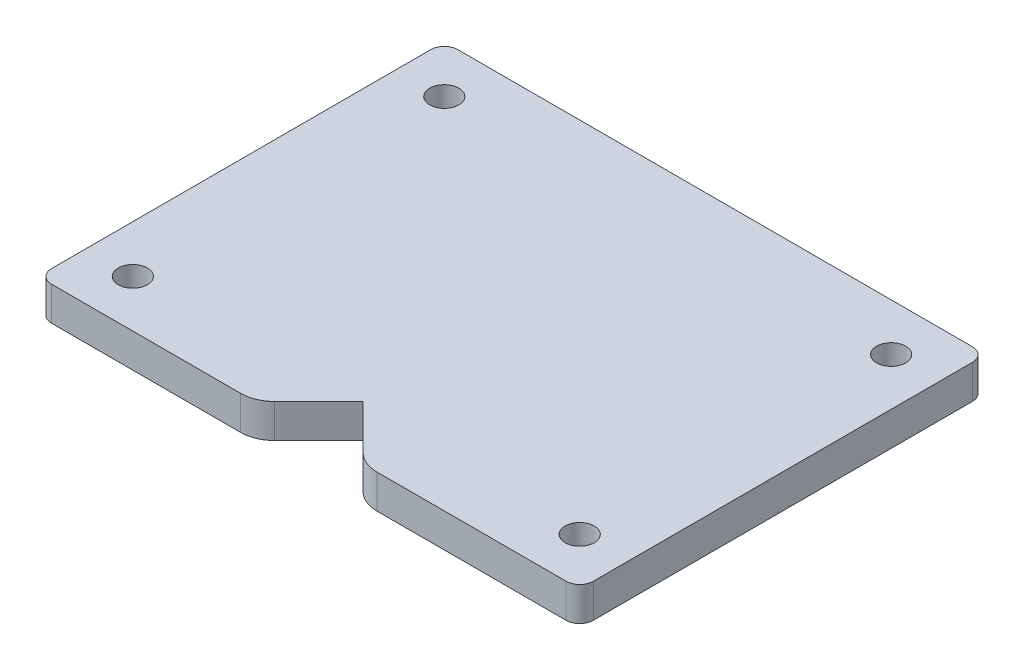
from build123d import *

# Parameters (mm, degrees)
SKETCH1_R           = 5.25
BOSS_EXTRUDE1_DEPTH = 60
SKETCH2_R           = 11.425
CUT_EXTRUDE1_DEPTH  = 8.6
SKETCH3_R           = 14
CUT_EXTRUDE2_DEPTH  = 5
SKETCH4_R           = 1.3
CUT_EXTRUDE3_DEPTH  = 5
SKETCH6_R           = 2.15
CUT_EXTRUDE5_DEPTH  = 6
CUT_EXTRUDE6_DEPTH  = 35
FILLET2_R           = 5
FILLET3_R           = 2
FILLET4_R           = 5
CUT_EXTRUDE7_DEPTH  = 30.05
FILLET5_R           = 5


with BuildPart() as part:
    # Sketch1 → Boss-Extrude1 (new body)
    with BuildSketch(Plane.XY):
        with BuildLine():
            Line((-40, 15.05), (40, 15.05))
            Line((40, 15.05), (40, 10.05))
            Line((40, 10.05), (9.746666097, 10.05))
            ThreePointArc((9.746666097, 10.05), (0, -14), (-9.746666097, 10.05))
            Line((-9.746666097, 10.05), (-40, 10.05))
            Line((-40, 10.05), (-40, 15.05))
        make_face()
        Circle(SKETCH1_R, mode=Mode.SUBTRACT)
    extrude(amount=BOSS_EXTRUDE1_DEPTH)

    # Sketch2 → Cut-Extrude1 (cut)
    with BuildSketch(Plane(origin=(0, 0, 0), x_dir=(-1, 0, 0), z_dir=(0, 0, -1))):
        Circle(SKETCH2_R)
    extrude(amount=-CUT_EXTRUDE1_DEPTH, mode=Mode.SUBTRACT)

    # Sketch3 → Cut-Extrude2 (cut)
    with BuildSketch(Plane(origin=(0, 0, 0), x_dir=(-1, 0, 0), z_dir=(0, 0, -1))):
        Circle(SKETCH3_R)
    extrude(amount=-CUT_EXTRUDE2_DEPTH, mode=Mode.SUBTRACT)

    # Sketch4 → Cut-Extrude3 (cut)
    with BuildSketch(Plane(origin=(0, 0, 8.6), x_dir=(-1, 0, 0), z_dir=(0, 0, -1))):
        with Locations((5.656854249, 5.656854249)):
            Circle(SKETCH4_R)
        with Locations((5.656854249, -5.656854249)):
            Circle(SKETCH4_R)
        with Locations((-5.656854249, -5.656854249)):
            Circle(SKETCH4_R)
        with Locations((-5.656854249, 5.656854249)):
            Circle(SKETCH4_R)
    extrude(amount=-CUT_EXTRUDE3_DEPTH, mode=Mode.SUBTRACT)

    # Sketch6 → Cut-Extrude5 (cut, through all)
    with BuildSketch(Plane(origin=(0, 10.05, 0), x_dir=(-1, 0, 0), z_dir=(0, -1, 0))):
        with Locations((33, -53)):
            Circle(SKETCH6_R)
        with Locations((33, -7)):
            Circle(SKETCH6_R)
        with Locations((-33, -53)):
            Circle(SKETCH6_R)
        with Locations((-33, -7)):
            Circle(SKETCH6_R)
    extrude(amount=-CUT_EXTRUDE5_DEPTH, mode=Mode.SUBTRACT)

    # Sketch7 → Cut-Extrude6 (cut)
    with BuildSketch(Plane.XY.offset(60)):
        with BuildLine():
            Line((-9.746666097, 10.05), (9.746666097, 10.05))
            ThreePointArc((9.746666097, 10.05), (0, -14), (-9.746666097, 10.05))
        make_face()
    extrude(amount=-CUT_EXTRUDE6_DEPTH, mode=Mode.SUBTRACT)

    # Fillet2
    fillet2_edges = [part.edges().sort_by_distance(p)[0] for p in [
        (9.746666097, 10.05, 15),
        (-9.746666097, 10.05, 15),
    ]]
    fillet(fillet2_edges, radius=FILLET2_R)

    # Fillet3
    fillet3_edges = [part.edges().sort_by_distance(p)[0] for p in [
        (40, 12.55, 60),
        (-40, 12.55, 60),
        (40, 12.55, 0),
        (-40, 12.55, 0),
    ]]
    fillet(fillet3_edges, radius=FILLET3_R)

    # Fillet4
    fillet4_edges = [part.edges().sort_by_distance(p)[0] for p in [
        (0, 10.05, 25),
    ]]
    fillet(fillet4_edges, radius=FILLET4_R)

    # Sketch8 → Cut-Extrude7 (cut, through all)
    with BuildSketch(Plane(origin=(0, 15.05, 0), x_dir=(1, 0, 0), z_dir=(0, 1, 0))):
        Polygon((0, -52), (8, -60), (-8, -60), align=None)
    extrude(amount=-CUT_EXTRUDE7_DEPTH, mode=Mode.SUBTRACT)

    # Fillet5
    fillet5_edges = [part.edges().sort_by_distance(p)[0] for p in [
        (-8, 12.55, 60),
        (8, 12.55, 60),
    ]]
    fillet(fillet5_edges, radius=FILLET5_R)


solid = part.part
